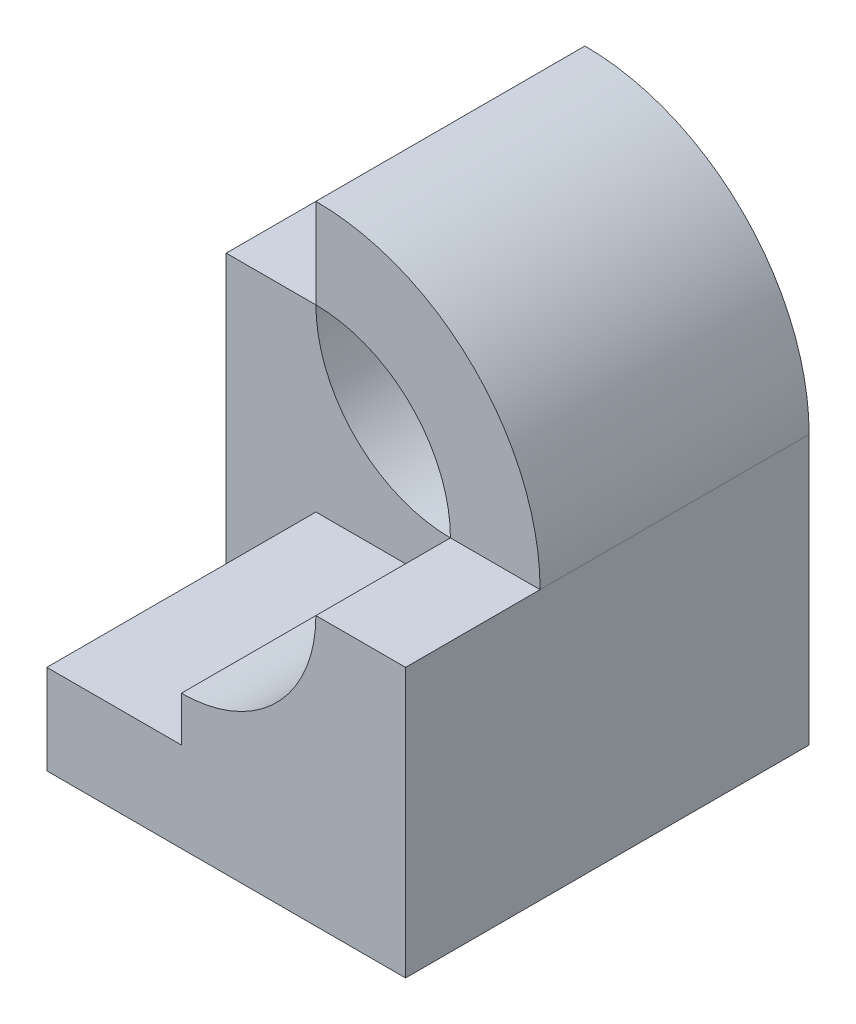
from build123d import *

# Parameters (mm, degrees)
BOSS_EXTRUDE1_DEPTH = 9
SKETCH2_W           = 5
SKETCH2_H           = 5
CUT_EXTRUDE1_DEPTH  = 3
CUT_EXTRUDE2_DEPTH  = 6


with BuildPart() as part:
    # Sketch1 → Boss-Extrude1 (new body)
    with BuildSketch(Plane.XY):
        with BuildLine():
            ThreePointArc((10, 6), (8.535533906, 9.535533906), (5, 11))
            Line((5, 11), (5, 9))
            ThreePointArc((5, 9), (7.121320344, 8.121320344), (8, 6))
            ThreePointArc((8, 6), (5, 3), (2, 6))
            Line((2, 6), (0, 6))
            Line((0, 6), (0, 0))
            Line((0, 0), (10, 0))
            Line((10, 0), (10, 6))
        make_face()
    extrude(amount=BOSS_EXTRUDE1_DEPTH)

    # Sketch2 → Cut-Extrude1 (cut)
    with BuildSketch(Plane.XY.offset(9)):
        with Locations((7.5, 8.5)):
            Rectangle(SKETCH2_W, SKETCH2_H)
    extrude(amount=-CUT_EXTRUDE1_DEPTH, mode=Mode.SUBTRACT)

    # Sketch3 → Cut-Extrude2 (cut)
    with BuildSketch(Plane.XY.offset(9)):
        Polygon((5, 3), (5, 2), (2, 2), (2, 0), (0, 0), (0, 6.616008908), (4.654546825, 5.714332837), align=None)
    extrude(amount=-CUT_EXTRUDE2_DEPTH, mode=Mode.SUBTRACT)


solid = part.part
